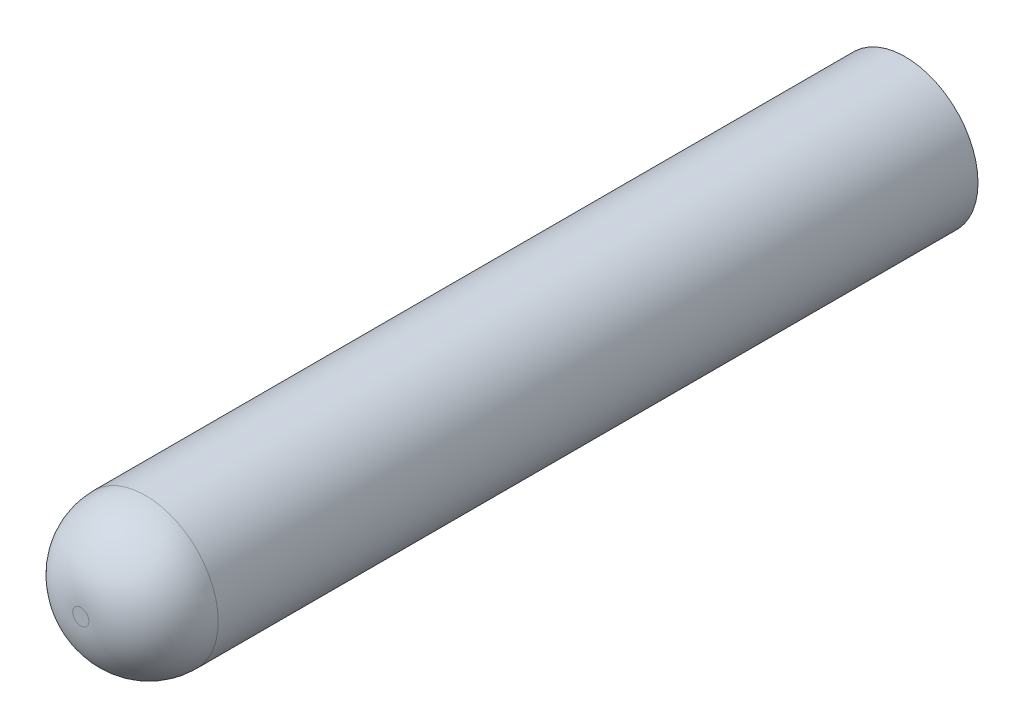
from build123d import *

# Parameters (mm, degrees)
SKETCH_1_R          = 2.25
EXTRUDE_2_DEPTH     = 25.5
SKETCH_7_W          = 2.4
SKETCH_7_H          = 2.4
CUT_EXTRUDE_3_DEPTH = 4.5
FILLET_2_R          = 2


with BuildPart() as part:
    # 草图1 → 凸台-拉伸2 (new body)
    with BuildSketch(Plane.XY):
        Circle(SKETCH_1_R)
    extrude(amount=EXTRUDE_2_DEPTH)

    # 草图7 → 切除-拉伸3 (cut)
    with BuildSketch(Plane.XY):
        Rectangle(SKETCH_7_W, SKETCH_7_H)
    extrude(amount=CUT_EXTRUDE_3_DEPTH, mode=Mode.SUBTRACT)

    # 圆角2
    fillet_2_edges = [part.edges().sort_by_distance(p)[0] for p in [
        (-2.25, 0, 25.5),
    ]]
    fillet(fillet_2_edges, radius=FILLET_2_R)


solid = part.part
